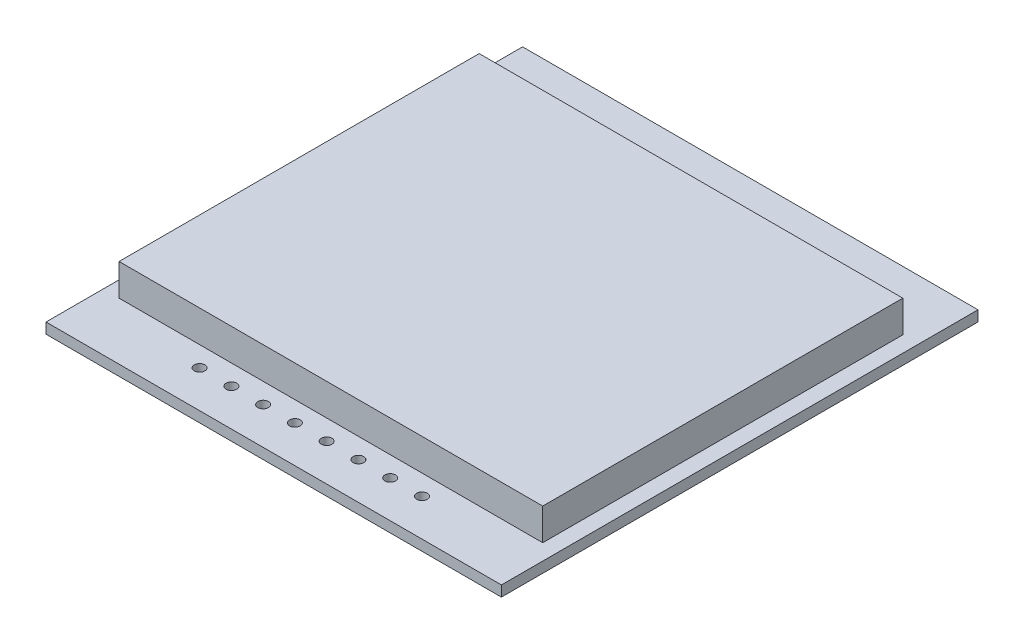
from build123d import *

# Parameters (mm, degrees)
CROQUIS1_W              = 43
CROQUIS1_H              = 45
SALIENTE_EXTRUIR1_DEPTH = 1
CROQUIS2_W              = 40
CROQUIS2_H              = 34
SALIENTE_EXTRUIR2_DEPTH = 3
CROQUIS3_R              = 0.5
CORTAR_EXTRUIR1_DEPTH   = 2


with BuildPart() as part:
    # Croquis1 → Saliente-Extruir1 (new body)
    with BuildSketch(Plane(origin=(0, 0, 0), x_dir=(1, 0, 0), z_dir=(0, 1, 0))):
        Rectangle(CROQUIS1_W, CROQUIS1_H)
    extrude(amount=SALIENTE_EXTRUIR1_DEPTH)

    # Croquis2 → Saliente-Extruir2 (add)
    with BuildSketch(Plane(origin=(0, 1, 0), x_dir=(1, 0, 0), z_dir=(0, 1, 0))):
        with Locations((0, -0.1)):
            Rectangle(CROQUIS2_W, CROQUIS2_H)
    extrude(amount=SALIENTE_EXTRUIR2_DEPTH)

    # Croquis3 → Cortar-Extruir1 (cut, through all)
    with BuildSketch(Plane(origin=(0, 1, 0), x_dir=(1, 0, 0), z_dir=(0, 1, 0))):
        with Locations((1.5, -19)):
            Circle(CROQUIS3_R)
        with Locations((4.5, -19)):
            Circle(CROQUIS3_R)
        with Locations((7.5, -19)):
            Circle(CROQUIS3_R)
        with Locations((10.5, -19)):
            Circle(CROQUIS3_R)
        with Locations((-10.5, -19)):
            Circle(CROQUIS3_R)
        with Locations((-7.5, -19)):
            Circle(CROQUIS3_R)
        with Locations((-4.5, -19)):
            Circle(CROQUIS3_R)
        with Locations((-1.5, -19)):
            Circle(CROQUIS3_R)
    extrude(amount=-CORTAR_EXTRUIR1_DEPTH, mode=Mode.SUBTRACT)


solid = part.part
